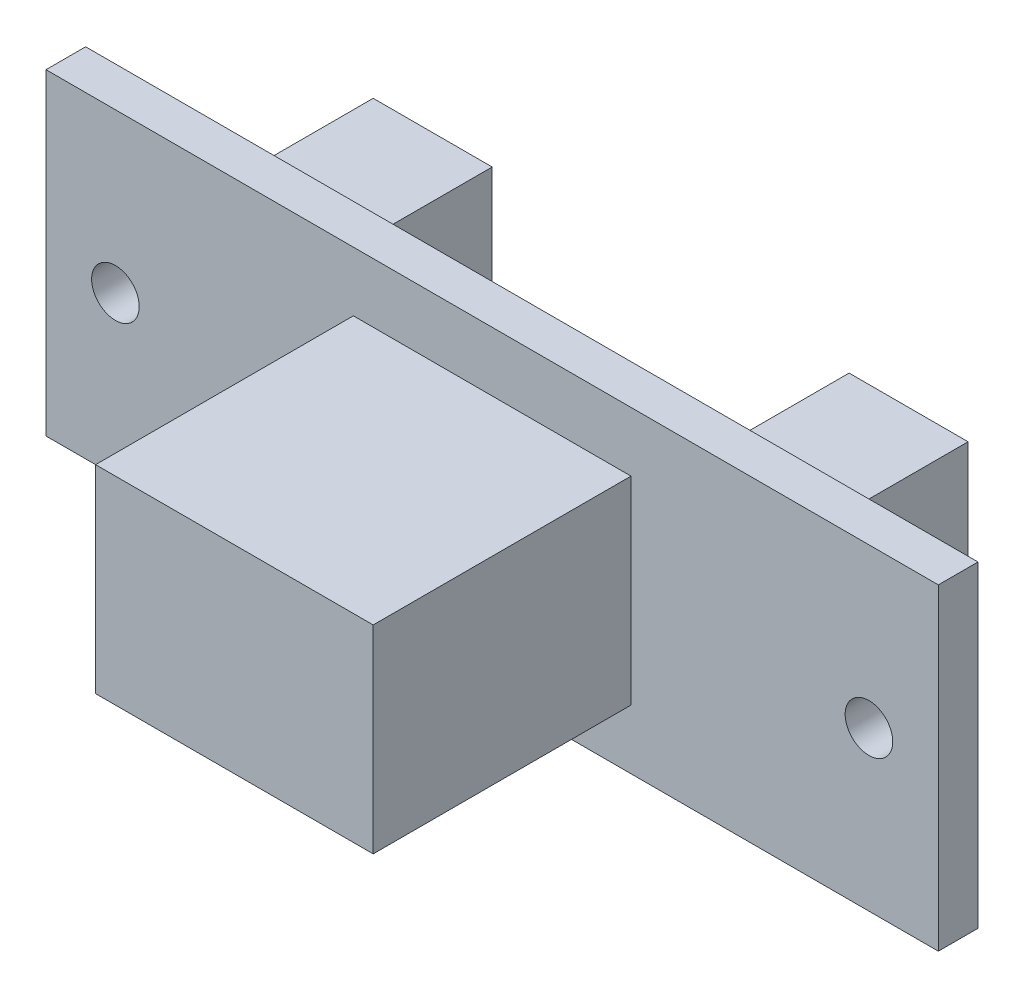
from build123d import *

# Parameters (mm, degrees)
SKETCH_1_W          = 45
SKETCH_1_H          = 16
EXTRUDE_1_DEPTH     = 2
SKETCH_2_R          = 1.2
CUT_EXTRUDE_1_DEPTH = 2
SKETCH_3_W          = 14
SKETCH_3_H          = 10
EXTRUDE_2_DEPTH     = 13
SKETCH_4_W          = 6
SKETCH_4_H          = 12
EXTRUDE_3_DEPTH     = 9


with BuildPart() as part:
    # ｽｹｯﾁ1 → ﾎﾞｽ - 押し出し1 (new body)
    with BuildSketch(Plane.XY):
        Rectangle(SKETCH_1_W, SKETCH_1_H)
    extrude(amount=EXTRUDE_1_DEPTH)

    # ｽｹｯﾁ2 → ｶｯﾄ - 押し出し1 (cut)
    with BuildSketch(Plane.XY.offset(2)):
        with Locations((-19, 0)):
            Circle(SKETCH_2_R)
        with Locations((19, 0)):
            Circle(SKETCH_2_R)
    extrude(amount=-CUT_EXTRUDE_1_DEPTH, mode=Mode.SUBTRACT)

    # ｽｹｯﾁ3 → ﾎﾞｽ - 押し出し2 (add)
    with BuildSketch(Plane.XY.offset(2)):
        Rectangle(SKETCH_3_W, SKETCH_3_H)
    extrude(amount=EXTRUDE_2_DEPTH)

    # ｽｹｯﾁ4 → ﾎﾞｽ - 押し出し3 (add)
    with BuildSketch(Plane.XY.offset(2)):
        with Locations((-12, 0)):
            Rectangle(SKETCH_4_W, SKETCH_4_H)
        with Locations((12, 0)):
            Rectangle(SKETCH_4_W, SKETCH_4_H)
    extrude(amount=-EXTRUDE_3_DEPTH)


solid = part.part
